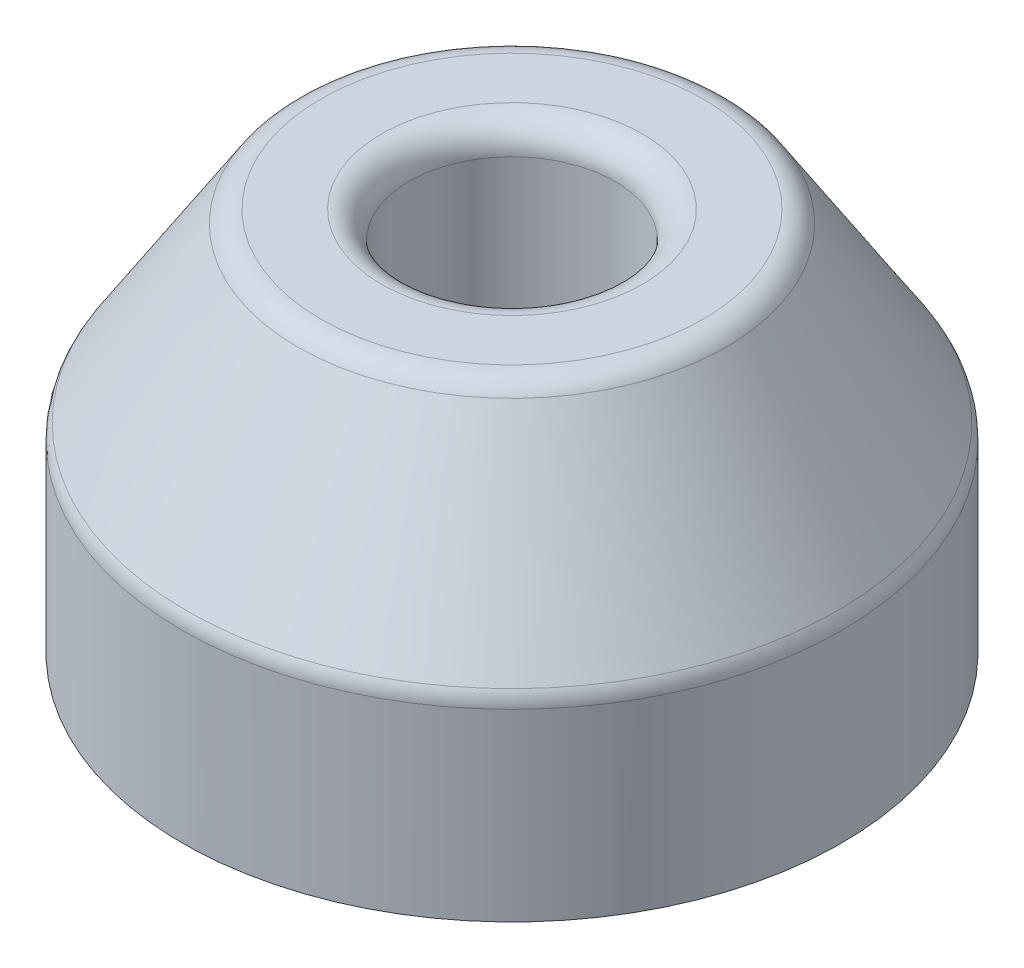
from build123d import *

# Parameters (mm, degrees)
SCHIZZO2_R               = 3.75
TAGLIO_ESTRUSIONE1_DEPTH = 8
FILLET1_R                = 1


with BuildPart() as part:
    # Schizzo1 → Rivoluzione1 (revolve)
    with BuildSketch(Plane.XY):
        Polygon((0, 0), (12, 0), (12, 7), (7.5, 14), (0, 14), align=None)
    revolve(axis=Axis((0, -9.987677887, 0), (0, 1, 0)))

    # Schizzo2 → Taglio-Estrusione1 (cut)
    with BuildSketch(Plane(origin=(0, 14, 0), x_dir=(1, 0, 0), z_dir=(0, 1, 0))):
        Circle(SCHIZZO2_R)
    extrude(amount=-TAGLIO_ESTRUSIONE1_DEPTH, mode=Mode.SUBTRACT)

    # Fillet1
    fillet1_edges = [part.edges().sort_by_distance(p)[0] for p in [
        (-3.75, 14, 0),
        (-7.5, 14, 0),
        (-12, 7, 0),
    ]]
    fillet(fillet1_edges, radius=FILLET1_R)


solid = part.part
